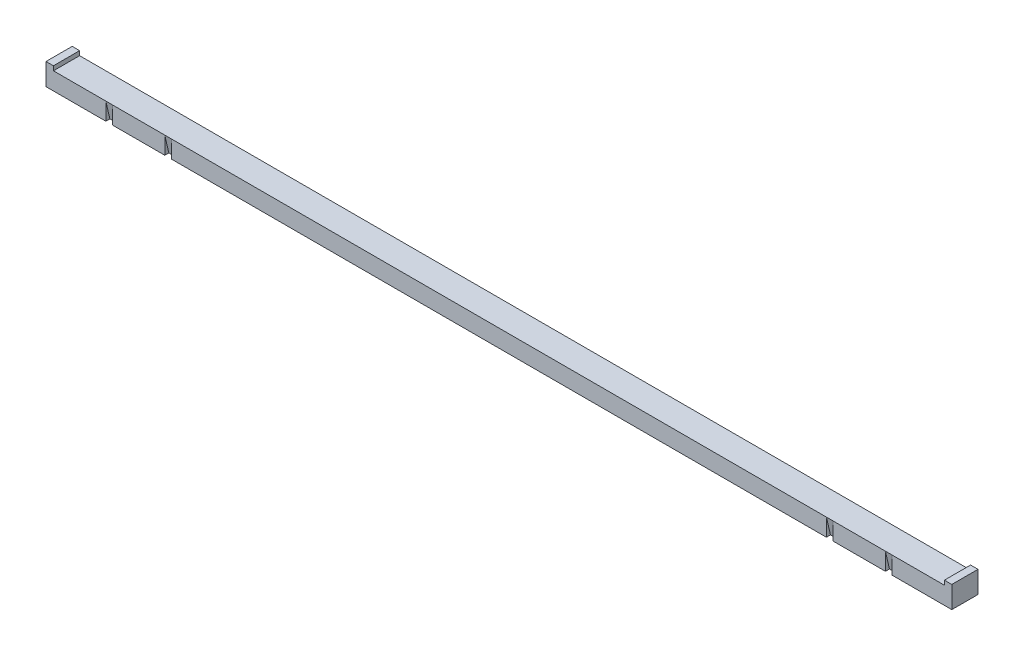
from build123d import *

# Parameters (mm, degrees)
SKETCH1_W           = 2633.98
SKETCH1_H           = 76.2
BOSS_EXTRUDE1_DEPTH = 50.8
SKETCH2_W           = 19.05
SKETCH2_H           = 63.5
CUT_REVOLVE4_ANGLE  = 103
SKETCH3_W           = 21.59
SKETCH3_H           = 76.2
BOSS_EXTRUDE2_DEPTH = 12.7


with BuildPart() as part:
    # Sketch1 → Boss-Extrude1 (new body)
    with BuildSketch(Plane(origin=(0, 0, 0), x_dir=(1, 0, 0), z_dir=(0, 1, 0))):
        Rectangle(SKETCH1_W, SKETCH1_H)
    extrude(amount=BOSS_EXTRUDE1_DEPTH)

    # Sketch2 → Cut-Revolve4 (revolve, cut)
    with BuildSketch(Plane(origin=(0, 50.8, 0), x_dir=(1, 0, 0), z_dir=(0, 1, 0))):
        with Locations((-962.025, -69.85)):
            Rectangle(SKETCH2_W, SKETCH2_H)
        with Locations((-1133.475, -69.85)):
            Rectangle(SKETCH2_W, SKETCH2_H)
        with Locations((962.025, -69.85)):
            Rectangle(SKETCH2_W, SKETCH2_H)
        with Locations((1133.475, -69.85)):
            Rectangle(SKETCH2_W, SKETCH2_H)
    revolve(axis=Axis((-1316.99, 50.8, 38.1), (1, 0, 0)), revolution_arc=CUT_REVOLVE4_ANGLE, mode=Mode.SUBTRACT)

    # Sketch3 → Boss-Extrude2 (add)
    with BuildSketch(Plane(origin=(0, 50.8, 0), x_dir=(1, 0, 0), z_dir=(0, 1, 0))):
        with Locations((-1306.195, 0)):
            Rectangle(SKETCH3_W, SKETCH3_H)
        with Locations((1306.195, 0)):
            Rectangle(SKETCH3_W, SKETCH3_H)
    extrude(amount=BOSS_EXTRUDE2_DEPTH)


solid = part.part
